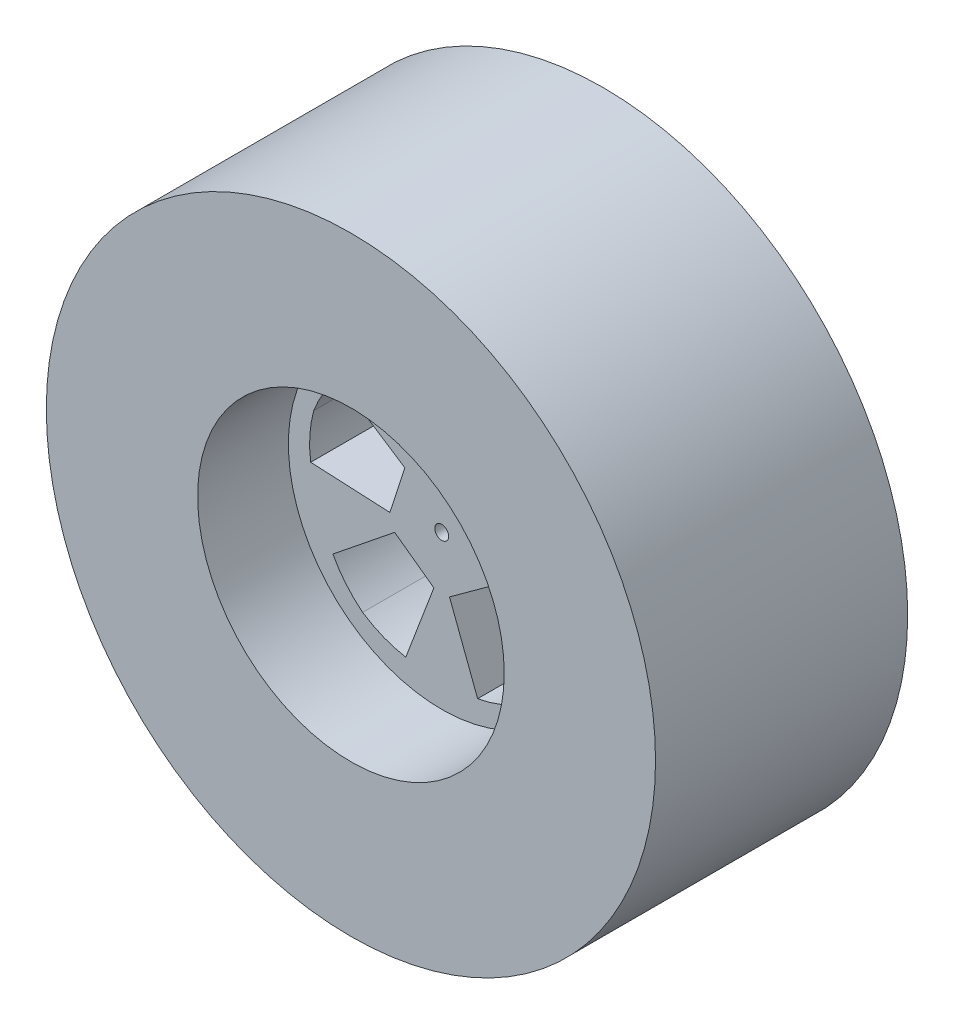
from build123d import *

# Parameters (mm, degrees)
BOSS_EXTRUDE1_DEPTH      = 250
BOSS_EXTRUDE1_DEPTH_BACK = 250
BOSS_EXTRUDE2_DEPTH      = 70
BOSS_EXTRUDE2_DEPTH_BACK = 70
CUT_EXTRUDE1_DEPTH       = 891.017977347
CUT_EXTRUDE1_DEPTH_BACK  = 80
SKETCH2_R                = 13.799006552


with BuildPart() as part:
    # Sketch1 → Boss-Extrude1 (new, two sides: drawn at the far end of the back side and taken through both)
    with BuildSketch(Plane.XY.offset(-BOSS_EXTRUDE1_DEPTH_BACK)):
        with BuildLine():
            ThreePointArc((604, 0), (427.092495837, 427.092495837), (0, 604))
            ThreePointArc((0, 604), (-427.092495837, -427.092495837), (604, 0))
        make_face()
        with BuildLine():
            ThreePointArc((-256.095528158, 163.801954987), (-145.979802856, 266.656890325), (0, 304))
            ThreePointArc((0, 304), (145.979802856, 266.656890325), (256.095528158, 163.801954987))
            ThreePointArc((256.095528158, 163.801954987), (291.778203915, 85.331586883), (304, 0))
            ThreePointArc((304, 0), (251.128651643, -171.319585349), (110.905261025, -283.047739926))
            ThreePointArc((110.905261025, -283.047739926), (0, -304), (-110.905261025, -283.047739926))
            ThreePointArc((-110.905261025, -283.047739926), (-289.121180954, -93.94116629), (-256.095528158, 163.801954987))
        make_face(mode=Mode.SUBTRACT)
    extrude(amount=BOSS_EXTRUDE1_DEPTH + BOSS_EXTRUDE1_DEPTH_BACK)

    # Sketch1_3 → Boss-Extrude2 (add, two sides: drawn at the far end of the back side and taken through both)
    with BuildSketch(Plane.XY.offset(-BOSS_EXTRUDE2_DEPTH_BACK)):
        with BuildLine():
            ThreePointArc((256.095528158, 163.801954987), (145.979802856, 266.656890325), (0, 304))
            ThreePointArc((0, 304), (-145.979802856, 266.656890325), (-256.095528158, 163.801954987))
            ThreePointArc((-256.095528158, 163.801954987), (-289.121180954, -93.94116629), (-110.905261025, -283.047739926))
            ThreePointArc((-110.905261025, -283.047739926), (0, -304), (110.905261025, -283.047739926))
            ThreePointArc((110.905261025, -283.047739926), (251.128651643, -171.319585349), (304, 0))
            ThreePointArc((304, 0), (291.778203915, 85.331586883), (256.095528158, 163.801954987))
        make_face()
        with BuildLine():
            Line((-215.721149564, -145.012778765), (-93.240227923, -46.571430252))
            Line((-93.240227923, -46.571430252), (-15.479247226, -103.068089747))
            Line((-15.479247226, -103.068089747), (-71.253846929, -249.974418035))
            add(Edge.make_bspline(
                [(-71.253846929, -249.974418035), (-117.347044344, -241.830887845), (-156.765760089, -215.769557936)],
                knots=[0, 0, 0, 1, 1, 1], degree=2))
            add(Edge.make_bspline(
                [(-215.721149564, -145.012778765), (-193.732610785, -186.3335253), (-156.765760089, -215.769557936)],
                knots=[0, 0, 0, 1, 1, 1], degree=2))
        make_face(mode=Mode.SUBTRACT)
        with BuildLine():
            Line((71.253846929, -249.974418035), (15.479247226, -103.068089747))
            Line((15.479247226, -103.068089747), (93.240227923, -46.571430252))
            Line((93.240227923, -46.571430252), (215.721149564, -145.012778765))
            add(Edge.make_bspline(
                [(215.721149564, -145.012778765), (193.732610785, -186.3335253), (156.765760089, -215.769557936)],
                knots=[0, 0, 0, 1, 1, 1], degree=2))
            add(Edge.make_bspline(
                [(71.253846929, -249.974418035), (117.347044344, -241.830887845), (156.765760089, -215.769557936)],
                knots=[0, 0, 0, 1, 1, 1], degree=2))
        make_face(mode=Mode.SUBTRACT)
        with BuildLine():
            Line((-204.576849452, 160.351591955), (-73.104877202, 74.285362947))
            Line((-73.104877202, 74.285362947), (-102.806928829, -17.128152368))
            Line((-102.806928829, -17.128152368), (-259.758448795, -9.479907899))
            add(Edge.make_bspline(
                [(-259.758448795, -9.479907899), (-266.257072669, 36.873817082), (-253.652328097, 82.416637394)],
                knots=[0, 0, 0, 1, 1, 1], degree=2))
            add(Edge.make_bspline(
                [(-204.576849452, 160.351591955), (-237.080382538, 126.670435966), (-253.652328097, 82.416637394)],
                knots=[0, 0, 0, 1, 1, 1], degree=2))
        make_face(mode=Mode.SUBTRACT)
        with BuildLine():
            Line((259.758448795, -9.479907899), (102.806928829, -17.128152368))
            Line((102.806928829, -17.128152368), (73.104877202, 74.285362947))
            Line((73.104877202, 74.285362947), (204.576849452, 160.351591955))
            add(Edge.make_bspline(
                [(204.576849452, 160.351591955), (237.080382538, 126.670435966), (253.652328097, 82.416637394)],
                knots=[0, 0, 0, 1, 1, 1], degree=2))
            add(Edge.make_bspline(
                [(259.758448795, -9.479907899), (266.257072669, 36.873817082), (253.652328097, 82.416637394)],
                knots=[0, 0, 0, 1, 1, 1], degree=2))
        make_face(mode=Mode.SUBTRACT)
        with BuildLine():
            Line((89.285703291, 244.115512743), (48.058929069, 92.48230942))
            Line((48.058929069, 92.48230942), (0, 92.48230942))
            Line((0, 92.48230942), (-48.058929069, 92.48230942))
            Line((-48.058929069, 92.48230942), (-89.285703291, 244.115512743))
            add(Edge.make_bspline(
                [(-89.285703291, 244.115512743), (-47.20887631, 264.620160097), (0, 266.705841084)],
                knots=[0, 0, 0, 1, 1, 1], degree=2))
            add(Edge.make_bspline(
                [(89.285703291, 244.115512743), (47.20887631, 264.620160097), (0, 266.705841084)],
                knots=[0, 0, 0, 1, 1, 1], degree=2))
        make_face(mode=Mode.SUBTRACT)
    extrude(amount=BOSS_EXTRUDE2_DEPTH + BOSS_EXTRUDE2_DEPTH_BACK)

    # Sketch2 → Cut-Extrude1 (cut, two sides: drawn at the far end of the back side and taken through both)
    with BuildSketch(Plane.XY.offset(-CUT_EXTRUDE1_DEPTH_BACK)):
        Circle(SKETCH2_R)
    extrude(amount=CUT_EXTRUDE1_DEPTH + CUT_EXTRUDE1_DEPTH_BACK, mode=Mode.SUBTRACT)


solid = part.part
